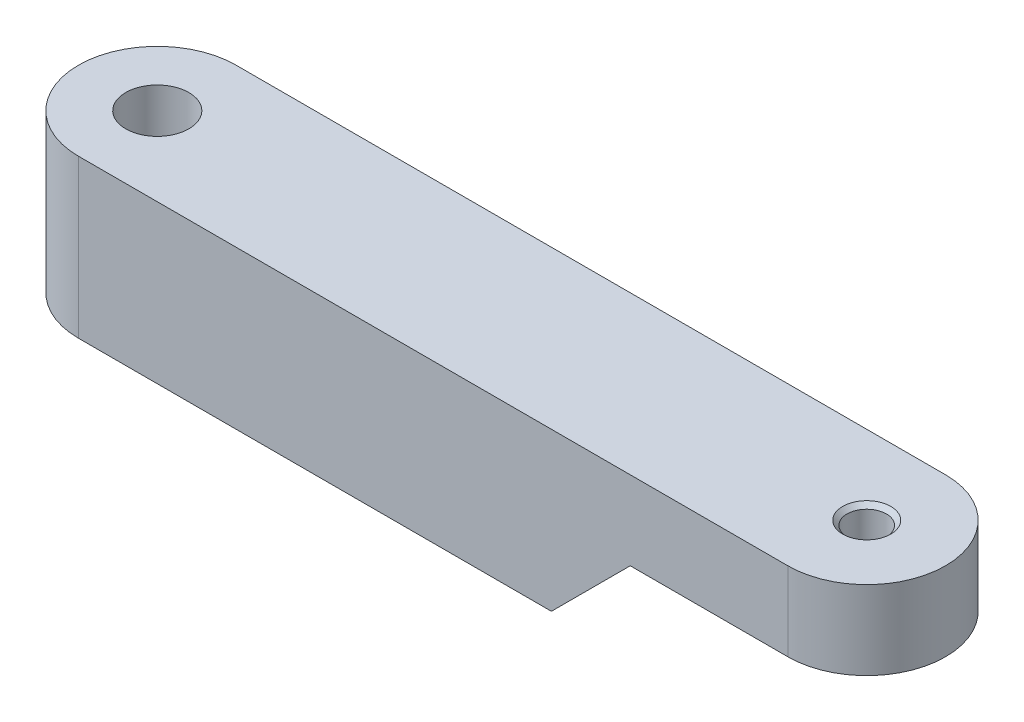
from build123d import *

# Parameters (mm, degrees)
ESQUISSE1_R                     = 2
BOSS_EXTRU_1_DEPTH              = 5
TROU_TARAUD_M3X0_51_D           = 2.5
TROU_TARAUD_M3X0_51_CSINK_D     = 3.05
TROU_TARAUD_M3X0_51_CSINK_ANGLE = 90
ENL_V_MAT_EXTRU_1_DEPTH         = 6
ENL_V_MAT_EXTRU_1_DEPTH_BACK    = 6


with BuildPart() as part:
    # Esquisse1 → Boss.-Extru.1 (new body, symmetric)
    with BuildSketch(Plane(origin=(0, 0, 0), x_dir=(1, 0, 0), z_dir=(0, 1, 0))):
        with BuildLine():
            Line((0, 5), (45, 5))
            ThreePointArc((45, 5), (50, 0), (45, -5))
            Line((45, -5), (0, -5))
            ThreePointArc((0, -5), (-5, 0), (0, 5))
        make_face()
        Circle(ESQUISSE1_R, mode=Mode.SUBTRACT)
    extrude(amount=BOSS_EXTRU_1_DEPTH, both=True)

    # Trou taraudé M3x0.51 (through all)
    with Locations(Plane(origin=(0, 5, 0), x_dir=(1, 0, 0), z_dir=(0, 1, 0))):
        with Locations((45, 0)):
            CounterSinkHole(TROU_TARAUD_M3X0_51_D / 2, TROU_TARAUD_M3X0_51_CSINK_D / 2, counter_sink_angle=TROU_TARAUD_M3X0_51_CSINK_ANGLE)

    # Esquisse4 → Enlèv. mat.-Extru.1 (cut, two sides)
    with BuildSketch(Plane.XY) as enl_v_mat_extru_1_sk:
        Polygon((35, 0), (50, 0), (50, -5), (30, -5), align=None)
    extrude(amount=ENL_V_MAT_EXTRU_1_DEPTH, mode=Mode.SUBTRACT)
    extrude(enl_v_mat_extru_1_sk.sketch, amount=-ENL_V_MAT_EXTRU_1_DEPTH_BACK, mode=Mode.SUBTRACT)


solid = part.part
